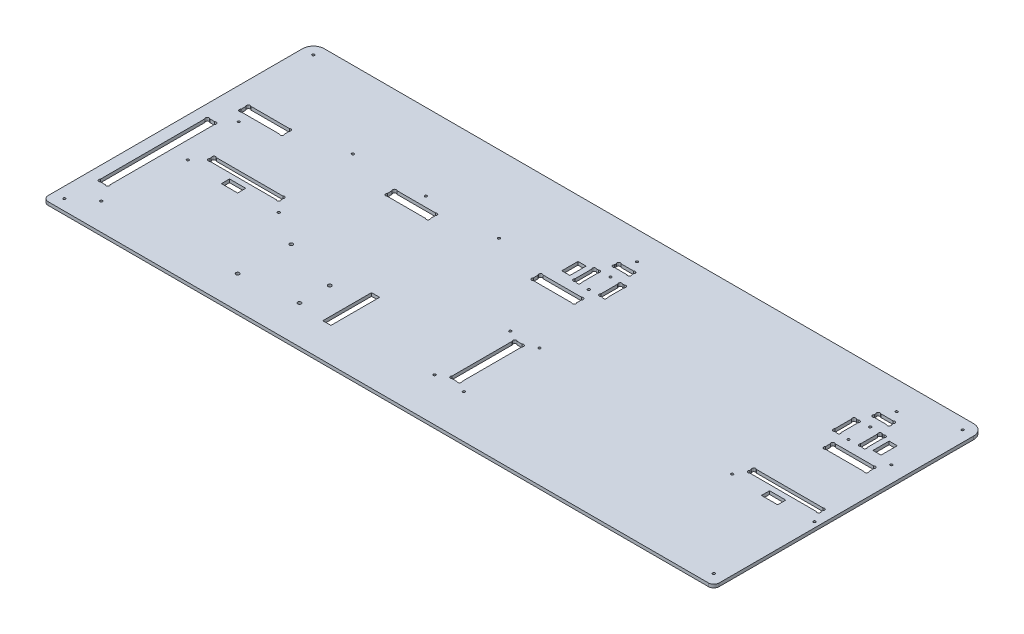
from build123d import *

# Parameters (mm, degrees)
ESQUISSE1_R             = 1.1
EXTRUSION1_DEPTH        = 3
ESQUISSE3_R             = 1.1
ENL_V_MAT_EXTRU_2_DEPTH = 4
CONG_1_R                = 5
ESQUISSE4_R             = 1.1
ENL_V_MAT_EXTRU_3_DEPTH = 4
ESQUISSE5_R             = 1.59
ENL_V_MAT_EXTRU_4_DEPTH = 4
ESQUISSE6_W             = 15
ESQUISSE6_H             = 7.5
ESQUISSE6_W_2           = 7.5
ESQUISSE6_H_2           = 15
ESQUISSE6_H_3           = 45
ENL_V_MAT_EXTRU_5_DEPTH = 4
ESQUISSE7_R             = 1.1
ENL_V_MAT_EXTRU_6_DEPTH = 4


with BuildPart() as part:
    # Esquisse1 → Extrusion1 (new body)
    with BuildSketch(Plane(origin=(0, 0, 0), x_dir=(1, 0, 0), z_dir=(0, 1, 0))):
        with BuildLine():
            Line((10, 250), (610, 250))
            ThreePointArc((610, 250), (617.071067812, 247.071067812), (620, 240))
            Line((620, 240), (620, 0))
            Line((620, 0), (0, 0))
            Line((0, 0), (0, 240))
            ThreePointArc((0, 240), (2.928932188, 247.071067812), (10, 250))
        make_face()
        with Locations(Location((539, 98, 0), (0, 0, 270))):  # turned: the seam where the file's is
            Circle(ESQUISSE1_R, mode=Mode.SUBTRACT)
        with Locations(Location((615, 98, 0), (0, 0, 270))):  # turned: the seam where the file's is
            Circle(ESQUISSE1_R, mode=Mode.SUBTRACT)
        with BuildLine():
            Line((317, 211.2627417), (317, 212.7372583))
            ThreePointArc((317, 212.7372583), (317, 215), (319.2627417, 215))
            Line((319.2627417, 215), (330.7372583, 215))
            ThreePointArc((330.7372583, 215), (333, 215), (333, 212.7372583))
            Line((333, 212.7372583), (333, 211.2627417))
            ThreePointArc((333, 211.2627417), (333, 209), (330.737258301, 209))
            Line((330.737258301, 209), (319.262741699, 209))
            ThreePointArc((319.262741699, 209), (316.999999999, 209.000000001), (317, 211.2627417))
        make_face(mode=Mode.SUBTRACT)
        with BuildLine():
            Line((312.262741699, 179.5), (313.737258301, 179.5))
            ThreePointArc((313.737258301, 179.5), (316.000000001, 179.500000001), (316, 181.762741701))
            Line((316, 181.762741701), (316, 197.237258299))
            ThreePointArc((316, 197.237258299), (316.000000001, 199.499999999), (313.737258301, 199.5))
            Line((313.737258301, 199.5), (312.262741699, 199.5))
            ThreePointArc((312.262741699, 199.5), (309.999999999, 199.499999999), (310, 197.237258299))
            Line((310, 197.237258299), (310, 181.762741701))
            ThreePointArc((310, 181.762741701), (309.999999999, 179.500000001), (312.262741699, 179.5))
        make_face(mode=Mode.SUBTRACT)
        with BuildLine():
            Line((334, 181.762741701), (334, 197.2372583))
            ThreePointArc((334, 197.2372583), (334, 199.5), (336.2627417, 199.5))
            Line((336.2627417, 199.5), (337.7372583, 199.5))
            ThreePointArc((337.7372583, 199.5), (340, 199.5), (340, 197.2372583))
            Line((340, 197.2372583), (340, 181.762741701))
            ThreePointArc((340, 181.762741701), (340.000000001, 179.500000001), (337.737258301, 179.5))
            Line((337.737258301, 179.5), (336.262741699, 179.5))
            ThreePointArc((336.262741699, 179.5), (333.999999999, 179.500000001), (334, 181.762741701))
        make_face(mode=Mode.SUBTRACT)
        with BuildLine():
            Line((552.2627417, 179.5), (553.7372583, 179.5))
            ThreePointArc((553.7372583, 179.5), (556, 179.5), (556, 181.7627417))
            Line((556, 181.7627417), (556, 197.2372583))
            ThreePointArc((556, 197.2372583), (556, 199.5), (553.7372583, 199.5))
            Line((553.7372583, 199.5), (552.2627417, 199.5))
            ThreePointArc((552.2627417, 199.5), (550, 199.5), (550, 197.2372583))
            Line((550, 197.2372583), (550, 181.7627417))
            ThreePointArc((550, 181.7627417), (550, 179.5), (552.2627417, 179.5))
        make_face(mode=Mode.SUBTRACT)
        with BuildLine():
            Line((574, 181.7627417), (574, 197.2372583))
            ThreePointArc((574, 197.2372583), (574, 199.5), (576.2627417, 199.5))
            Line((576.2627417, 199.5), (577.7372583, 199.5))
            ThreePointArc((577.7372583, 199.5), (580, 199.5), (580, 197.2372583))
            Line((580, 197.2372583), (580, 181.7627417))
            ThreePointArc((580, 181.7627417), (580, 179.5), (577.7372583, 179.5))
            Line((577.7372583, 179.5), (576.2627417, 179.5))
            ThreePointArc((576.2627417, 179.5), (574, 179.5), (574, 181.7627417))
        make_face(mode=Mode.SUBTRACT)
        with BuildLine():
            Line((559.2627417, 209), (570.7372583, 209))
            ThreePointArc((570.7372583, 209), (573, 209), (573, 211.2627417))
            Line((573, 211.2627417), (573, 212.7372583))
            ThreePointArc((573, 212.7372583), (573, 215), (570.7372583, 215))
            Line((570.7372583, 215), (559.2627417, 215))
            ThreePointArc((559.2627417, 215), (557, 215), (557, 212.7372583))
            Line((557, 212.7372583), (557, 211.2627417))
            ThreePointArc((557, 211.2627417), (557, 209), (559.2627417, 209))
        make_face(mode=Mode.SUBTRACT)
        with BuildLine():
            Line((560, 167.7372583), (560, 163.2627417))
            ThreePointArc((560, 163.2627417), (560, 161), (562.2627417, 161))
            Line((562.2627417, 161), (597.7372583, 161))
            ThreePointArc((597.7372583, 161), (600, 161), (600, 163.2627417))
            Line((600, 163.2627417), (600, 167.7372583))
            ThreePointArc((600, 167.7372583), (600, 170), (597.7372583, 170))
            Line((597.7372583, 170), (562.2627417, 170))
            ThreePointArc((562.2627417, 170), (560, 170), (560, 167.7372583))
        make_face(mode=Mode.SUBTRACT)
        with BuildLine():
            Line((292.2627417, 161), (327.7372583, 161))
            ThreePointArc((327.7372583, 161), (330, 161), (330, 163.2627417))
            Line((330, 163.2627417), (330, 167.7372583))
            ThreePointArc((330, 167.7372583), (330, 170), (327.7372583, 170))
            Line((327.7372583, 170), (292.2627417, 170))
            ThreePointArc((292.2627417, 170), (290, 170), (290, 167.7372583))
            Line((290, 167.7372583), (290, 163.2627417))
            ThreePointArc((290, 163.2627417), (290, 161), (292.2627417, 161))
        make_face(mode=Mode.SUBTRACT)
        with BuildLine():
            Line((20, 167.7372583), (20, 163.2627417))
            ThreePointArc((20, 163.2627417), (20, 161), (22.2627417, 161))
            Line((22.2627417, 161), (57.7372583, 161))
            ThreePointArc((57.7372583, 161), (60, 161), (60, 163.2627417))
            Line((60, 163.2627417), (60, 167.7372583))
            ThreePointArc((60, 167.7372583), (60, 170), (57.7372583, 170))
            Line((57.7372583, 170), (22.2627417, 170))
            ThreePointArc((22.2627417, 170), (20, 170), (20, 167.7372583))
        make_face(mode=Mode.SUBTRACT)
        with BuildLine():
            Line((155, 167.7372583), (155, 163.2627417))
            ThreePointArc((155, 163.2627417), (155, 161), (157.2627417, 161))
            Line((157.2627417, 161), (192.7372583, 161))
            ThreePointArc((192.7372583, 161), (195, 161), (195, 163.2627417))
            Line((195, 163.2627417), (195, 167.7372583))
            ThreePointArc((195, 167.7372583), (195, 170), (192.7372583, 170))
            Line((192.7372583, 170), (157.2627417, 170))
            ThreePointArc((157.2627417, 170), (155, 170), (155, 167.7372583))
        make_face(mode=Mode.SUBTRACT)
        with BuildLine():
            Line((13.2627417, 40), (17.7372583, 40))
            ThreePointArc((17.7372583, 40), (20, 40), (20, 42.2627417))
            Line((20, 42.2627417), (20, 138.7372583))
            ThreePointArc((20, 138.7372583), (20, 141), (17.7372583, 141))
            Line((17.7372583, 141), (13.2627417, 141))
            ThreePointArc((13.2627417, 141), (11, 141), (11, 138.7372583))
            Line((11, 138.7372583), (11, 42.2627417))
            ThreePointArc((11, 42.2627417), (11, 40), (13.2627417, 40))
        make_face(mode=Mode.SUBTRACT)
        with BuildLine():
            Line((337.7372583, 45), (333.2627417, 45))
            ThreePointArc((333.2627417, 45), (331, 45), (331, 47.2627417))
            Line((331, 47.2627417), (331, 102.7372583))
            ThreePointArc((331, 102.7372583), (331, 105), (333.2627417, 105))
            Line((333.2627417, 105), (337.7372583, 105))
            ThreePointArc((337.7372583, 105), (340, 105), (340, 102.7372583))
            Line((340, 102.7372583), (340, 47.2627417))
            ThreePointArc((340, 47.2627417), (340, 45), (337.7372583, 45))
        make_face(mode=Mode.SUBTRACT)
        with BuildLine():
            Line((610, 109.2627417), (610, 110.7372583))
            ThreePointArc((610, 110.7372583), (610, 113), (607.7372583, 113))
            Line((607.7372583, 113), (546.2627417, 113))
            ThreePointArc((546.2627417, 113), (544, 113), (544, 110.7372583))
            Line((544, 110.7372583), (544, 109.2627417))
            ThreePointArc((544, 109.2627417), (544, 107), (546.2627417, 107))
            Line((546.2627417, 107), (607.7372583, 107))
            ThreePointArc((607.7372583, 107), (610, 107), (610, 109.2627417))
        make_face(mode=Mode.SUBTRACT)
        with BuildLine():
            Line((108.7372583, 113), (47.2627417, 113))
            ThreePointArc((47.2627417, 113), (45, 113), (45, 110.7372583))
            Line((45, 110.7372583), (45, 109.2627417))
            ThreePointArc((45, 109.2627417), (45, 107), (47.2627417, 107))
            Line((47.2627417, 107), (108.7372583, 107))
            ThreePointArc((108.7372583, 107), (111, 107), (111, 109.2627417))
            Line((111, 109.2627417), (111, 110.7372583))
            ThreePointArc((111, 110.7372583), (111, 113), (108.7372583, 113))
        make_face(mode=Mode.SUBTRACT)
    extrude(amount=EXTRUSION1_DEPTH)

    # Esquisse3 → Enlèv. mat.-Extru.2 (cut, through all)
    with BuildSketch(Plane(origin=(0, 3, 0), x_dir=(1, 0, 0), z_dir=(0, 1, 0))):
        with Locations(Location((565, 179.5, 0), (0, 0, 270))):  # turned: the seam where the file's is
            Circle(ESQUISSE3_R)
        with Locations(Location((565, 199.5, 0), (0, 0, 270))):  # turned: the seam where the file's is
            Circle(ESQUISSE3_R)
        with Locations(Location((325, 179.5, 0), (0, 0, 270))):  # turned: the seam where the file's is
            Circle(ESQUISSE3_R)
        with Locations(Location((325, 199.5, 0), (0, 0, 270))):  # turned: the seam where the file's is
            Circle(ESQUISSE3_R)
    extrude(amount=-ENL_V_MAT_EXTRU_2_DEPTH, mode=Mode.SUBTRACT)

    # Congé1
    cong_1_edges = [part.edges().sort_by_distance(p)[0] for p in [
        (620, 1.5, 0),
        (0, 1.5, 0),
    ]]
    fillet(cong_1_edges, radius=CONG_1_R)

    # Esquisse4 → Enlèv. mat.-Extru.3 (cut, through all)
    with BuildSketch(Plane.XZ):
        with Locations(Location((10, -10, 0), (0, 0, 270))):  # turned: the seam where the file's is
            Circle(ESQUISSE4_R)
        with Locations(Location((610, -10, 0), (0, 0, 270))):  # turned: the seam where the file's is
            Circle(ESQUISSE4_R)
        with Locations(Location((610, -240, 0), (0, 0, 270))):  # turned: the seam where the file's is
            Circle(ESQUISSE4_R)
        with Locations(Location((10, -240, 0), (0, 0, 270))):  # turned: the seam where the file's is
            Circle(ESQUISSE4_R)
    extrude(amount=-ENL_V_MAT_EXTRU_3_DEPTH, mode=Mode.SUBTRACT)

    # Esquisse5 → Enlèv. mat.-Extru.4 (cut, through all)
    with BuildSketch(Plane(origin=(0, 3, 0), x_dir=(1, 0, 0), z_dir=(0, 1, 0))):
        with Locations(Location((151.27, 78.26, 0), (0, 0, 270))):  # turned: the seam where the file's is
            Circle(ESQUISSE5_R)
        with Locations(Location((150, 30, 0), (0, 0, 270))):  # turned: the seam where the file's is
            Circle(ESQUISSE5_R)
        with Locations(Location((202.07, 63.02, 0), (0, 0, 270))):  # turned: the seam where the file's is
            Circle(ESQUISSE5_R)
        with Locations(Location((202.07, 35.08, 0), (0, 0, 270))):  # turned: the seam where the file's is
            Circle(ESQUISSE5_R)
    extrude(amount=-ENL_V_MAT_EXTRU_4_DEPTH, mode=Mode.SUBTRACT)

    # Esquisse6 → Enlèv. mat.-Extru.5 (cut, through all)
    with BuildSketch(Plane(origin=(0, 3, 0), x_dir=(1, 0, 0), z_dir=(0, 1, 0))):
        with Locations((577, 98.25)):
            Rectangle(ESQUISSE6_W, ESQUISSE6_H)
        with Locations((588.75, 189.5)):
            Rectangle(ESQUISSE6_W_2, ESQUISSE6_H_2)
        with Locations((301.25, 189.5)):
            Rectangle(ESQUISSE6_W_2, ESQUISSE6_H_2)
        with Locations((230.82, 54.13)):
            Rectangle(ESQUISSE6_W_2, ESQUISSE6_H_3)
        with Locations((78, 98.25)):
            Rectangle(ESQUISSE6_W, ESQUISSE6_H)
    extrude(amount=-ENL_V_MAT_EXTRU_5_DEPTH, mode=Mode.SUBTRACT)

    # Esquisse7 → Enlèv. mat.-Extru.6 (cut, through all)
    with BuildSketch(Plane(origin=(0, 3, 0), x_dir=(1, 0, 0), z_dir=(0, 1, 0))):
        with Locations(Location((349, 110, 0), (0, 0, 270))):  # turned: the seam where the file's is
            Circle(ESQUISSE7_R)
        with Locations(Location((349, 40, 0), (0, 0, 270))):  # turned: the seam where the file's is
            Circle(ESQUISSE7_R)
        with Locations(Location((322, 110, 0), (0, 0, 270))):  # turned: the seam where the file's is
            Circle(ESQUISSE7_R)
        with Locations(Location((322, 40, 0), (0, 0, 270))):  # turned: the seam where the file's is
            Circle(ESQUISSE7_R)
        with Locations(Location((605, 179, 0), (0, 0, 270))):  # turned: the seam where the file's is
            Circle(ESQUISSE7_R)
        with Locations(Location((565, 224, 0), (0, 0, 270))):  # turned: the seam where the file's is
            Circle(ESQUISSE7_R)
        with Locations(Location((325, 224, 0), (0, 0, 270))):  # turned: the seam where the file's is
            Circle(ESQUISSE7_R)
        with Locations(Location((175, 179, 0), (0, 0, 270))):  # turned: the seam where the file's is
            Circle(ESQUISSE7_R)
        with Locations(Location((242.5, 179, 0), (0, 0, 270))):  # turned: the seam where the file's is
            Circle(ESQUISSE7_R)
        with Locations(Location((107.5, 179, 0), (0, 0, 270))):  # turned: the seam where the file's is
            Circle(ESQUISSE7_R)
        with Locations(Location((120, 98, 0), (0, 0, 270))):  # turned: the seam where the file's is
            Circle(ESQUISSE7_R)
        with Locations(Location((36, 98, 0), (0, 0, 270))):  # turned: the seam where the file's is
            Circle(ESQUISSE7_R)
        with Locations(Location((29, 152, 0), (0, 0, 270))):  # turned: the seam where the file's is
            Circle(ESQUISSE7_R)
        with Locations(Location((29, 25, 0), (0, 0, 270))):  # turned: the seam where the file's is
            Circle(ESQUISSE7_R)
    extrude(amount=-ENL_V_MAT_EXTRU_6_DEPTH, mode=Mode.SUBTRACT)


solid = part.part
